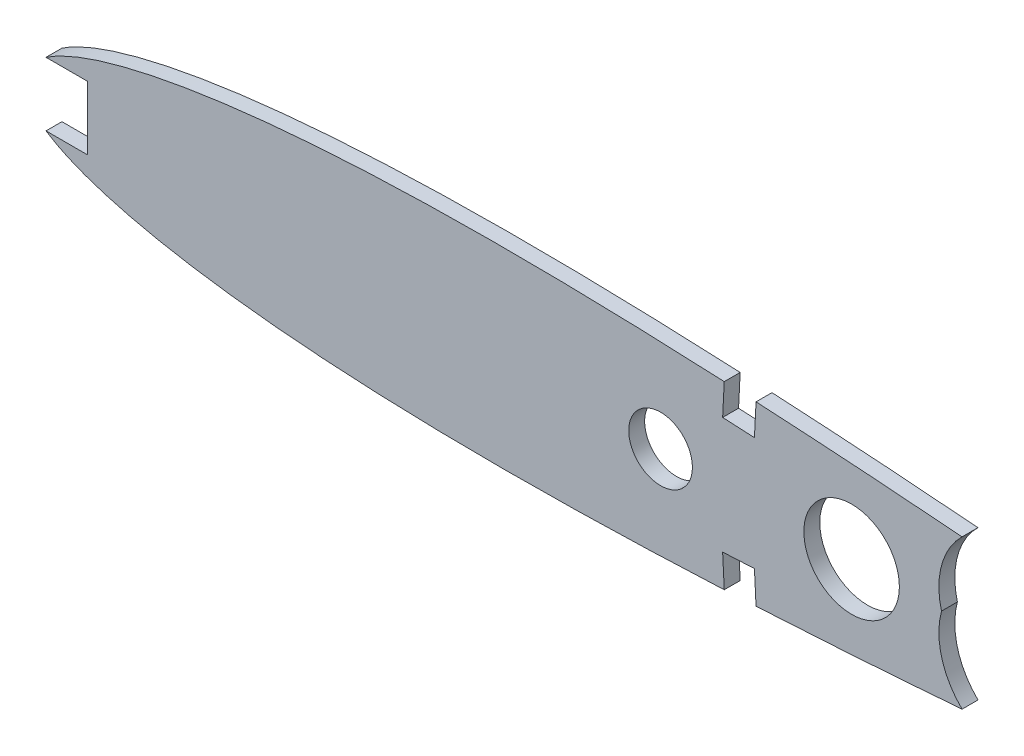
from build123d import *

# Parameters (mm, degrees)
BOSS_EXTRUDE1_DEPTH = 3.175
SKETCH3_R           = 6.35
CUT_EXTRUDE1_DEPTH  = 4.1750001
SKETCH4_W           = 12.7
SKETCH4_H           = 12.7
CUT_EXTRUDE2_DEPTH  = 4.1750001
CUT_EXTRUDE3_DEPTH  = 4.1750001
SKETCH9_R           = 9.525
CUT_EXTRUDE5_DEPTH  = 5.08


with BuildPart() as part:
    # Sketch2 → Boss-Extrude1 (new body)
    with BuildSketch(Plane.XY):
        with BuildLine():
            add(Edge.make_bspline(
                [(318.77, 0.4016502), (318.651672051, 0.500810625), (317.887139521, 0.407183952), (316.525702267, 0.790429835), (314.029007456, 1.027310814), (310.665580368, 1.535686456), (306.332982445, 2.102999714), (301.108142881, 2.802187224), (295.00465514, 3.592552282), (288.066717306, 4.4725213), (280.334877508, 5.426678676), (271.857503414, 6.442111261), (262.686702585, 7.506224727), (252.87894916, 8.604531435), (242.494745532, 9.723621949), (231.598187206, 10.849597023), (220.25642858, 11.967923085), (208.539426289, 13.062902197), (196.51933871, 14.120159542), (184.270405083, 15.122019671), (171.867889749, 16.052147213), (159.388371015, 16.893273609), (146.908740176, 17.627811631), (134.505824677, 18.237204103), (122.256224526, 18.705201007), (110.2351092, 19.016534527), (98.516766738, 19.155997955), (87.173201506, 19.112523415), (76.274349541, 18.877713447), (65.887298252, 18.445615875), (56.075981931, 17.815100401), (46.900701285, 16.988064202), (38.417602501, 15.970966467), (30.678392783, 14.772461193), (23.72996987, 13.405065743), (17.613059426, 11.884241622), (12.362420389, 10.224818762), (8.00472945, 8.442252382), (4.553883407, 6.548602381), (2.01519229, 4.54013128), (0.389181285, 2.368249597), (-0.181372316, 0), (0.389181285, -2.368249597), (2.01519229, -4.54013128), (4.553883407, -6.548602381), (8.00472945, -8.442252382), (12.362420389, -10.224818762), (17.613059426, -11.884241622), (23.72996987, -13.405065743), (30.678392783, -14.772461193), (38.417602501, -15.970966467), (46.900701285, -16.988064202), (56.075981931, -17.815100401), (65.887298252, -18.445615875), (76.274349541, -18.877713447), (87.173201506, -19.112523415), (98.516766738, -19.155997955), (110.2351092, -19.016534527), (122.256224526, -18.705201007), (134.505824677, -18.237204103), (146.908740176, -17.627811631), (159.388371015, -16.893273609), (171.867889749, -16.052147213), (184.270405083, -15.122019671), (196.51933871, -14.120159542), (208.539426289, -13.062902197), (220.25642858, -11.967923085), (231.598187206, -10.849597023), (242.494745532, -9.723621949), (252.87894916, -8.604531435), (262.686702585, -7.506224727), (271.857503414, -6.442111261), (280.334877508, -5.426678676), (288.066717306, -4.4725213), (295.00465514, -3.592552282), (301.108142881, -2.802187224), (306.332982445, -2.102999714), (310.665580368, -1.535686456), (314.029007456, -1.027310814), (316.525702267, -0.790429835), (317.887139521, -0.407183952), (318.96162857, -0.538768719), (318.96162857, 0.241062861), (318.77, 0.4016502)],
                knots=[0, 0, 0, 0, 0.000762215, 0.003044706, 0.006832246, 0.012101176, 0.018817536, 0.026939455, 0.036414848, 0.047184629, 0.059180413, 0.072327874, 0.086544061, 0.10174058, 0.117823336, 0.134691452, 0.152240154, 0.17036129, 0.188941008, 0.207865435, 0.227016078, 0.246275696, 0.265524943, 0.284644966, 0.303520118, 0.322034575, 0.340078353, 0.357542593, 0.374325482, 0.390329891, 0.40546389, 0.419643801, 0.432793371, 0.444843817, 0.455737921, 0.465428653, 0.47388632, 0.481101634, 0.487101684, 0.491975368, 0.495930678, 0.499382808, 0.502834938, 0.506790248, 0.511663932, 0.517663982, 0.524879296, 0.533336963, 0.543027695, 0.553921799, 0.565972245, 0.579121815, 0.593301726, 0.608435725, 0.624440134, 0.641223023, 0.658687263, 0.676731041, 0.695245498, 0.71412065, 0.733240673, 0.75248992, 0.771749538, 0.790900181, 0.809824608, 0.828404326, 0.846525462, 0.864074164, 0.88094228, 0.897025036, 0.912221555, 0.926437743, 0.939585203, 0.951580988, 0.962350768, 0.971826161, 0.979948081, 0.98666444, 0.991933371, 0.99572091, 0.998003402, 0.998765616, 1, 1, 1, 1], degree=3))
        make_face()
    extrude(amount=BOSS_EXTRUDE1_DEPTH)

    # Sketch3 → Cut-Extrude1 (cut, through all)
    with BuildSketch(Plane.XY.offset(3.175)):
        with Locations((127, 0)):
            Circle(SKETCH3_R)
        Polygon((146.041832216, 17.654123083), (145.719448384, 11.304123083), (139.377616168, 11.626092244), (139.7, 17.976092244), (139.972135492, 23.336349817), (146.313967709, 23.014380656), align=None)
        Polygon((145.719448384, -11.304123083), (139.377616168, -11.626092244), (139.7, -17.976092244), (139.876824838, -21.459014187), (146.218657054, -21.137045026), (146.041832216, -17.654123083), align=None)
    extrude(amount=-CUT_EXTRUDE1_DEPTH, mode=Mode.SUBTRACT)

    # Sketch4 → Cut-Extrude2 (cut, through all)
    with BuildSketch(Plane.XY.offset(3.175)):
        with Locations((6.35, 0)):
            Rectangle(SKETCH4_W, SKETCH4_H)
    extrude(amount=-CUT_EXTRUDE2_DEPTH, mode=Mode.SUBTRACT)

    # Sketch5 → Cut-Extrude3 (cut, through all)
    with BuildSketch(Plane.XY.offset(3.175)):
        with BuildLine():
            Line((188.763328764, 17.093497057), (187.34983048, 15.089350861))
            ThreePointArc((187.34983048, 15.089350861), (183.094624601, 8.144494137), (183.023721428, 0))
            ThreePointArc((183.023721428, 0), (183.072311074, -8.06586998), (187.230894162, -14.977223407))
            Line((187.230894162, -14.977223407), (188.588975382, -18.075111724))
            add(Edge.make_bspline(
                [(188.588975382, -18.075111724), (191.824355535, -17.830310957), (199.841087156, -17.206236773), (212.516511905, -16.154636366), (226.466564745, -14.920704924), (239.970203835, -13.65677605), (252.944086016, -12.381118049), (265.308209748, -11.110630122), (276.986217406, -9.861474653), (287.906030173, -8.649252334), (298.000356614, -7.490870717), (307.207112828, -6.401010018), (315.468663619, -5.394751924), (322.736664519, -4.490202252), (328.958509167, -3.688972861), (334.117780822, -3.039413883), (338.123361689, -2.454274616), (341.095902765, -2.187108839), (342.718315982, -1.739066598), (343.996214648, -1.901995728), (344.002571846, -0.619693067), (342.723120546, -0.769943771), (341.105229436, -0.305837259), (338.135483436, -0.009211749), (334.135901144, 0.615614253), (328.983323498, 1.316295691), (322.769728908, 2.179175541), (315.511053915, 3.155743275), (307.259886312, 4.24386552), (298.064388673, 5.42495801), (287.982043821, 6.683368345), (277.074787054, 8.003801467), (265.409738858, 9.368683456), (253.058819828, 10.761699723), (240.098223582, 12.165931591), (226.607780172, 13.563687468), (212.670647531, 14.9358736), (200.006272506, 16.113099669), (191.996122671, 16.816629398), (188.763328764, 17.093497057)],
                knots=[0.797255798, 0.797255798, 0.797255798, 0.797255798, 0.809824608, 0.828404326, 0.846525462, 0.864074164, 0.88094228, 0.897025036, 0.912221555, 0.926437743, 0.939585203, 0.951580988, 0.962350768, 0.971826161, 0.979948081, 0.98666444, 0.991933371, 0.99572091, 0.998003402, 0.998765616, 1, 1.000762215, 1.003044706, 1.006832246, 1.012101176, 1.018817536, 1.026939455, 1.036414848, 1.047184629, 1.059180413, 1.072327874, 1.086544061, 1.10174058, 1.117823336, 1.134691452, 1.152240154, 1.17036129, 1.188941008, 1.201509818, 1.201509818, 1.201509818, 1.201509818], degree=3))
        make_face()
    extrude(amount=-CUT_EXTRUDE3_DEPTH, mode=Mode.SUBTRACT)

    # Sketch9 → Cut-Extrude5 (cut)
    with BuildSketch(Plane.XY.offset(3.175)):
        with Locations((165.1, 0)):
            Circle(SKETCH9_R)
    extrude(amount=-CUT_EXTRUDE5_DEPTH, mode=Mode.SUBTRACT)


solid = part.part
